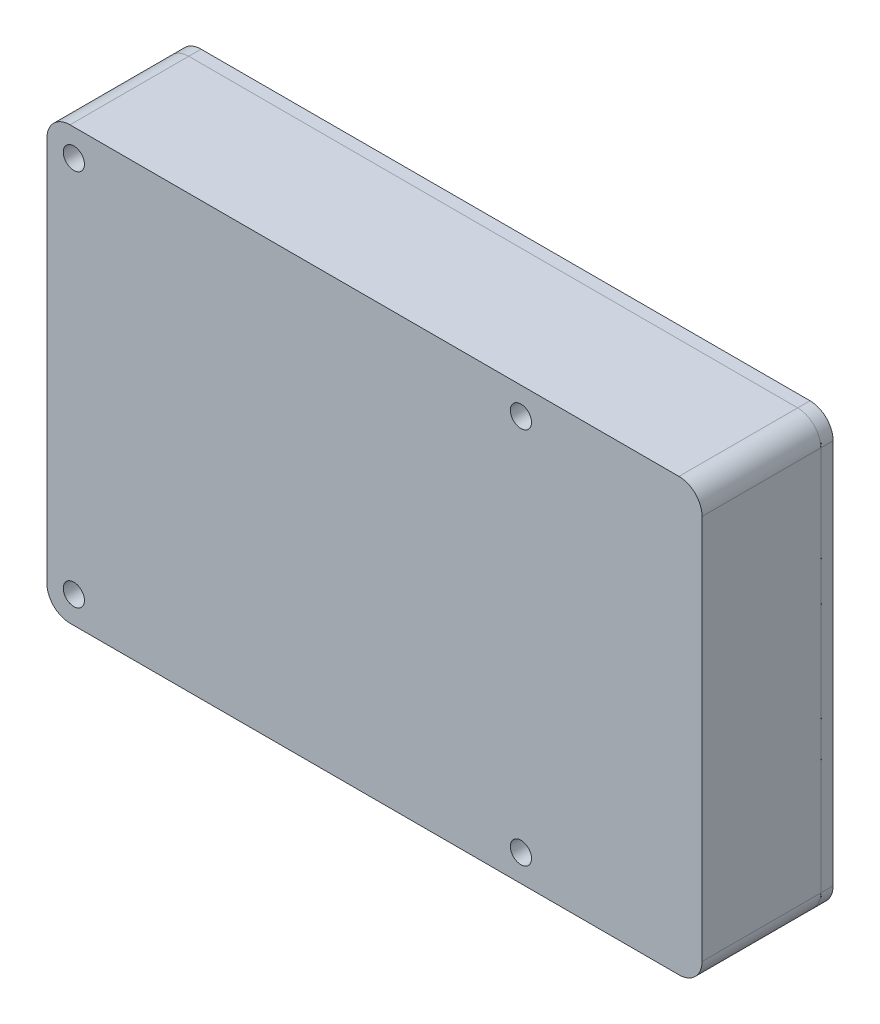
from build123d import *

# Parameters (mm, degrees)
SKETCH1_R           = 1.375
BOSS_EXTRUDE1_DEPTH = 1.6
CUT_EXTRUDE1_DEPTH  = 0.1
SKETCH_1_R          = 1.375
EXTRUDE_1_DEPTH     = 15.4


with BuildPart() as part:
    # Sketch1 → Boss-Extrude1 (new body)
    with BuildSketch(Plane.XY):
        with BuildLine():
            Line((-39.5, -28), (39.5, -28))
            ThreePointArc((39.5, -28), (41.621320344, -27.121320344), (42.5, -25))
            Line((42.5, -25), (42.5, 25))
            ThreePointArc((42.5, 25), (41.621320344, 27.121320344), (39.5, 28))
            Line((39.5, 28), (-39.5, 28))
            ThreePointArc((-39.5, 28), (-41.621320344, 27.121320344), (-42.5, 25))
            Line((-42.5, 25), (-42.5, -25))
            ThreePointArc((-42.5, -25), (-41.621320344, -27.121320344), (-39.5, -28))
        make_face()
        with Locations((-39, 24.5)):
            Circle(SKETCH1_R, mode=Mode.SUBTRACT)
        with Locations((-39, -24.5)):
            Circle(SKETCH1_R, mode=Mode.SUBTRACT)
        with Locations((19, 24.5)):
            Circle(SKETCH1_R, mode=Mode.SUBTRACT)
        with Locations((19, -24.5)):
            Circle(SKETCH1_R, mode=Mode.SUBTRACT)
    extrude(amount=BOSS_EXTRUDE1_DEPTH)

    # Sketch2 → Cut-Extrude1 (cut)
    with BuildSketch(Plane.XY.offset(1.6)):
        Polygon((-35.65, -28.636850855), (-28.15, -28.636850855), (-28.15, -23.2), (-31.573707352, -23.2), (-31.573707352, -23.3), (-28.25, -23.3), (-28.25, -28.536850855), (-35.55, -28.536850855), (-35.55, -23.3), (-32.465045999, -23.3), (-32.465045999, -23.2), (-35.65, -23.2), align=None)
        Polygon((-17.75, -17.5), (-11.015830732, -17.5), (-11.015830732, -17.6), (-17.65, -17.6), (-17.65, -33.061376344), (-3.35, -33.061376344), (-3.35, -17.6), (-9.684859924, -17.6), (-9.684859924, -17.5), (-3.25, -17.5), (-3.25, -33.161376344), (-17.75, -33.161376344), align=None)
        Polygon((0.5, -5.3), (4.5, -5.3), (4.5, -27.7), (0.5, -27.7), (0.5, -17.125), (0.6, -17.125), (0.6, -27.6), (4.4, -27.6), (4.4, -5.4), (0.6, -5.4), (0.6, -15.17398131), (0.5, -15.17398131), align=None)
        Polygon((7.5, -15.5), (9.799158316, -15.5), (9.799158316, -15.6), (7.6, -15.6), (7.6, -31.061376344), (14.4, -31.061376344), (14.4, -15.6), (12.062610562, -15.6), (12.062610562, -15.5), (14.5, -15.5), (14.5, -31.161376344), (7.5, -31.161376344), align=None)
        Polygon((-35.45, 27), (15.45, 27), (15.45, 22), (-8.906687942, 22), (-8.906687942, 22.1), (15.35, 22.1), (15.35, 26.9), (-35.35, 26.9), (-35.35, 22.1), (-11.458179647, 22.1), (-11.458179647, 22), (-35.45, 22), align=None)
        Polygon((-41.371710411, -10.514157593), (-37.371710411, -10.514157593), (-37.371710411, 0.094714316), (-37.471710411, 0.094714316), (-37.471710411, -10.414157593), (-41.271710411, -10.414157593), (-41.271710411, 10.414157593), (-37.471710411, 10.414157593), (-37.471710411, 1), (-37.371710411, 1), (-37.371710411, 10.514157593), (-41.371710411, 10.514157593), align=None)
        Polygon((23.2, -25.5), (44.7, -25.5), (44.7, -10), (23.2, -10), (23.2, -16.5), (23.3, -16.5), (23.3, -10.1), (44.6, -10.1), (44.6, -25.4), (23.3, -25.4), (23.3, -17.75), (23.2, -17.75), align=None)
        Polygon((26.8, -5.5), (54.071370237, -5.5), (54.071370237, 7.5), (26.8, 7.5), (26.8, 2.552788505), (26.9, 2.552788505), (26.9, 7.4), (53.971370237, 7.4), (53.971370237, -5.4), (26.9, -5.4), (26.9, 0.407211154), (26.8, 0.407211154), align=None)
        Polygon((26.8, 12.5), (57.71374017, 12.5), (57.71374017, 25.5), (26.8, 25.5), (26.8, 20.277341759), (26.9, 20.277341759), (26.9, 25.4), (57.61374017, 25.4), (57.61374017, 12.6), (26.9, 12.6), (26.9, 18.611308355), (26.8, 18.611308355), align=None)
    extrude(amount=-CUT_EXTRUDE1_DEPTH, mode=Mode.SUBTRACT)


with BuildPart() as body_2:
    # Эскиз1 → Бобышка-Вытянуть1 (new body)
    with BuildSketch(Plane.XY.offset(1.6)):
        with BuildLine():
            Line((-39.5, -28), (39.5, -28))
            ThreePointArc((39.5, -28), (41.621320344, -27.121320344), (42.5, -25))
            Line((42.5, -25), (42.5, 25))
            ThreePointArc((42.5, 25), (41.621320344, 27.121320344), (39.5, 28))
            Line((39.5, 28), (-39.5, 28))
            ThreePointArc((-39.5, 28), (-41.621320344, 27.121320344), (-42.5, 25))
            Line((-42.5, 25), (-42.5, -25))
            ThreePointArc((-42.5, -25), (-41.621320344, -27.121320344), (-39.5, -28))
        make_face()
        with Locations((19, -24.5)):
            Circle(SKETCH_1_R, mode=Mode.SUBTRACT)
        with Locations((-39, -24.5)):
            Circle(SKETCH_1_R, mode=Mode.SUBTRACT)
        with Locations((-39, 24.5)):
            Circle(SKETCH_1_R, mode=Mode.SUBTRACT)
        with Locations((19, 24.5)):
            Circle(SKETCH_1_R, mode=Mode.SUBTRACT)
    extrude(amount=EXTRUDE_1_DEPTH)


solid = Compound([part.part, body_2.part])
